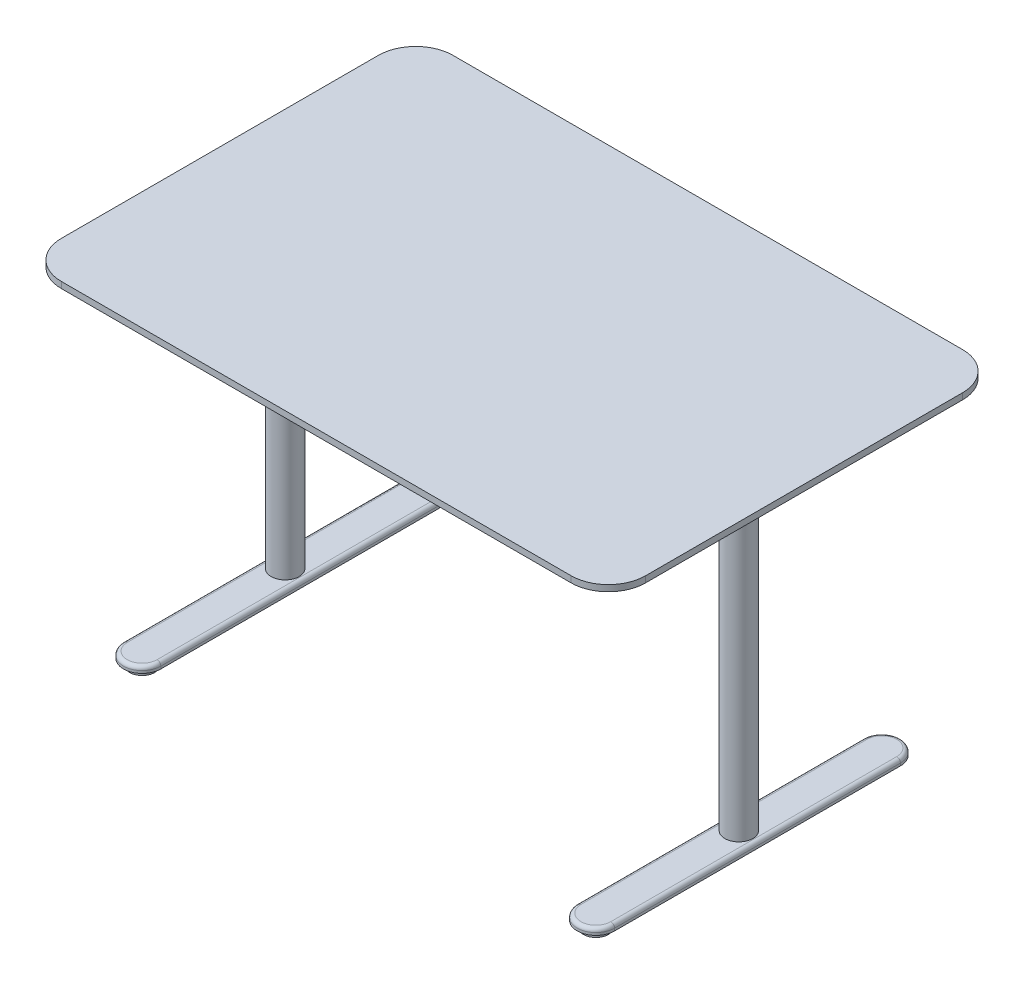
from build123d import *

# Parameters (mm, degrees)
BOSS_EXTRUDE1_DEPTH   = 12.7
SKETCH2_W             = 1054.1
SKETCH2_H             = 457.2
SKETCH2_W_2           = 990.6
SKETCH2_H_2           = 393.7
EXTRUDE_THIN1_DEPTH   = 31.75
SKETCH3_W             = 31.75
SKETCH3_H             = 393.7
BOSS_EXTRUDE2_DEPTH   = 31.75
BOSS_EXTRUDE2_2_DEPTH = 31.75
SKETCH4_W             = 63.5
SKETCH4_H             = 88.9
BOSS_EXTRUDE3_DEPTH   = 12.7
BOSS_EXTRUDE3_2_DEPTH = 12.7
SKETCH5_R             = 28.575
BOSS_EXTRUDE4_DEPTH   = 635
BOSS_EXTRUDE4_2_DEPTH = 635
BOSS_EXTRUDE5_DEPTH   = 12.7
BOSS_EXTRUDE5_2_DEPTH = 12.7
SKETCH7_R             = 25.4
BOSS_EXTRUDE6_DEPTH   = 12.7
FILLET1_R             = 7.62
FILLET2_R             = 7.62


with BuildPart() as part:
    # Sketch1 → Boss-Extrude1 (new body)
    with BuildSketch(Plane(origin=(0, 0, 0), x_dir=(1, 0, 0), z_dir=(0, 1, 0))):
        with BuildLine():
            Line((-520.7, 400.05), (520.7, 400.05))
            ThreePointArc((520.7, 400.05), (574.581536726, 377.731536726), (596.9, 323.85))
            Line((596.9, 323.85), (596.9, -323.85))
            ThreePointArc((596.9, -323.85), (574.581536726, -377.731536726), (520.7, -400.05))
            Line((520.7, -400.05), (-520.7, -400.05))
            ThreePointArc((-520.7, -400.05), (-574.581536726, -377.731536726), (-596.9, -323.85))
            Line((-596.9, -323.85), (-596.9, 323.85))
            ThreePointArc((-596.9, 323.85), (-574.581536726, 377.731536726), (-520.7, 400.05))
        make_face()
    extrude(amount=-BOSS_EXTRUDE1_DEPTH)

    # Sketch2 → Extrude-Thin1 (add)
    with BuildSketch(Plane.XZ.offset(12.7)):
        Rectangle(SKETCH2_W, SKETCH2_H)
        Rectangle(SKETCH2_W_2, SKETCH2_H_2, mode=Mode.SUBTRACT)
    extrude(amount=EXTRUDE_THIN1_DEPTH)


with BuildPart() as body_2:
    # Sketch3 → Boss-Extrude2 (new body)
    with BuildSketch(Plane.XZ.offset(12.7)):
        with Locations((-415.925, 0)):
            Rectangle(SKETCH3_W, SKETCH3_H)
    extrude(amount=BOSS_EXTRUDE2_DEPTH)


with BuildPart() as body_3:
    # Sketch3 → Boss-Extrude2 2 (new body)
    with BuildSketch(Plane.XZ.offset(12.7)):
        with Locations((415.925, 0)):
            Rectangle(SKETCH3_W, SKETCH3_H)
    extrude(amount=BOSS_EXTRUDE2_2_DEPTH)


with BuildPart() as body_4:
    # Sketch4 → Boss-Extrude3 (new body)
    with BuildSketch(Plane.XZ.offset(44.45)):
        with Locations((-463.55, 0)):
            Rectangle(SKETCH4_W, SKETCH4_H)
    extrude(amount=-BOSS_EXTRUDE3_DEPTH)


with BuildPart() as body_5:
    # Sketch4 → Boss-Extrude3 2 (new body)
    with BuildSketch(Plane.XZ.offset(44.45)):
        with Locations((463.55, 0)):
            Rectangle(SKETCH4_W, SKETCH4_H)
    extrude(amount=-BOSS_EXTRUDE3_2_DEPTH)


with BuildPart() as body_6:
    # Sketch5 → Boss-Extrude4 (new body)
    with BuildSketch(Plane.XZ.offset(44.45)):
        with Locations(Location((-463.55, 0, 0), (0, 0, 270))):  # turned: the seam where the file's is
            Circle(SKETCH5_R)
    extrude(amount=BOSS_EXTRUDE4_DEPTH)


with BuildPart() as body_7:
    # Sketch5 → Boss-Extrude4 2 (new body)
    with BuildSketch(Plane.XZ.offset(44.45)):
        with Locations(Location((463.55, 0, 0), (0, 0, 90))):  # turned: the seam where the file's is
            Circle(SKETCH5_R)
    extrude(amount=BOSS_EXTRUDE4_2_DEPTH)


with BuildPart() as body_8:
    # Sketch6 → Boss-Extrude5 (new body)
    with BuildSketch(Plane.XZ.offset(679.45)):
        with BuildLine():
            Line((-501.65, -292.1), (-501.65, 292.1))
            ThreePointArc((-501.65, 292.1), (-463.55, 330.2), (-425.45, 292.1))
            Line((-425.45, 292.1), (-425.45, -292.1))
            ThreePointArc((-425.45, -292.1), (-463.55, -330.2), (-501.65, -292.1))
        make_face()
    extrude(amount=BOSS_EXTRUDE5_DEPTH)



with BuildPart() as body_9:
    # Sketch6 → Boss-Extrude5 2 (new body)
    with BuildSketch(Plane.XZ.offset(679.45)):
        with BuildLine():
            Line((501.65, -292.1), (501.65, 292.1))
            ThreePointArc((501.65, 292.1), (463.55, 330.2), (425.45, 292.1))
            Line((425.45, 292.1), (425.45, -292.1))
            ThreePointArc((425.45, -292.1), (463.55, -330.2), (501.65, -292.1))
        make_face()
    extrude(amount=BOSS_EXTRUDE5_2_DEPTH)


with BuildPart() as body_8_1:
    add(body_8.part)

    add(body_9.part)  # Boss-Extrude6 merges body 9
    # Sketch7 → Boss-Extrude6 (add)
    with BuildSketch(Plane.XZ.offset(692.15)):
        with Locations(Location((-463.55, 292.1, 0), (0, 0, 270))):  # turned: the seam where the file's is
            Circle(SKETCH7_R)
        with Locations(Location((-463.55, -292.1, 0), (0, 0, 270))):  # turned: the seam where the file's is
            Circle(SKETCH7_R)
        with Locations(Location((463.55, -292.1, 0), (0, 0, 90))):  # turned: the seam where the file's is
            Circle(SKETCH7_R)
        with Locations(Location((463.55, 292.1, 0), (0, 0, 90))):  # turned: the seam where the file's is
            Circle(SKETCH7_R)
    extrude(amount=BOSS_EXTRUDE6_DEPTH)

    # Fillet1
    fillet1_edges = [body_8_1.edges().sort_by_distance(p)[0] for p in [
        (-501.65, -679.45, 0),
        (-463.55, -679.45, 330.2),
        (-425.45, -679.45, 0),
        (-463.55, -679.45, -330.2),
    ]]
    fillet(fillet1_edges, radius=FILLET1_R)

    # Fillet2
    fillet2_edges = [body_8_1.edges().sort_by_distance(p)[0] for p in [
        (425.45, -679.45, 0),
        (463.55, -679.45, 330.2),
        (501.65, -679.45, 0),
        (463.55, -679.45, -330.2),
    ]]
    fillet(fillet2_edges, radius=FILLET2_R)


solid = Compound([part.part, body_2.part, body_3.part, body_4.part, body_5.part, body_6.part, body_7.part, body_8_1.part])
